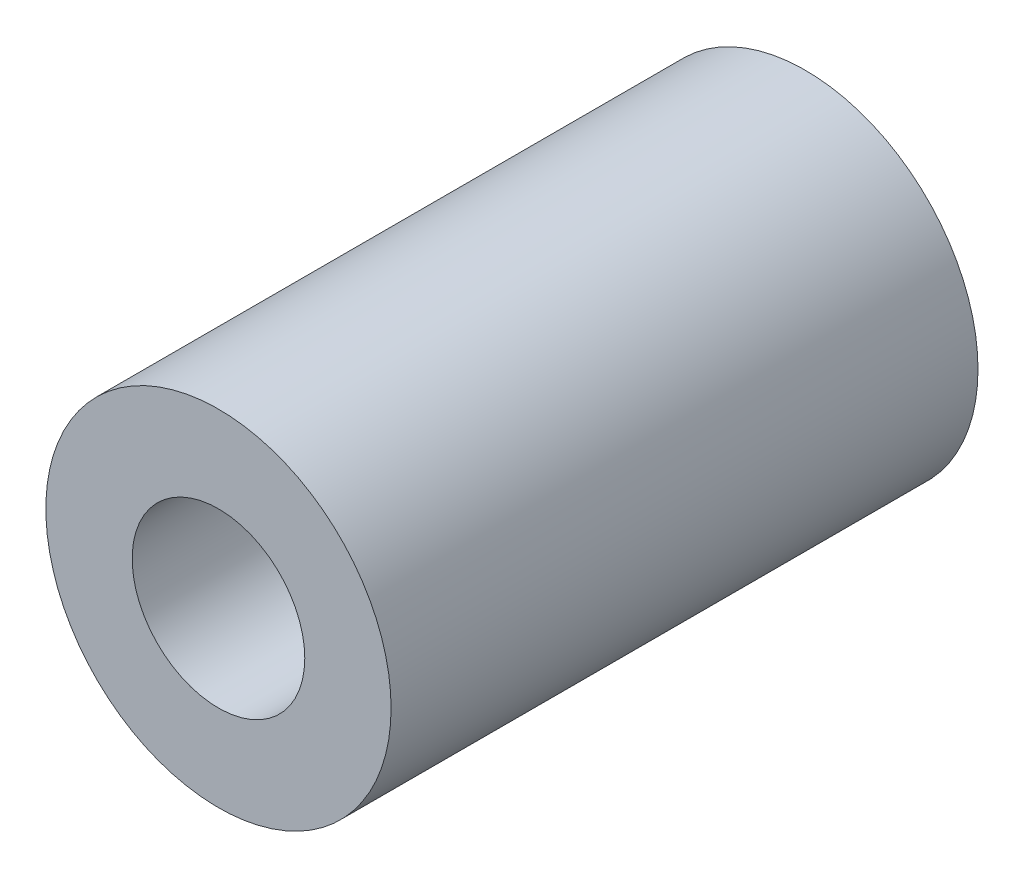
from build123d import *

# Parameters (mm, degrees)
SKETCH_1_R      = 5
SKETCH_1_R_2    = 2.5
EXTRUDE_1_DEPTH = 17


with BuildPart() as part:
    # ｽｹｯﾁ1 → ﾎﾞｽ - 押し出し1 (new body)
    with BuildSketch(Plane.XY):
        Circle(SKETCH_1_R)
        Circle(SKETCH_1_R_2, mode=Mode.SUBTRACT)
    extrude(amount=EXTRUDE_1_DEPTH)


solid = part.part
